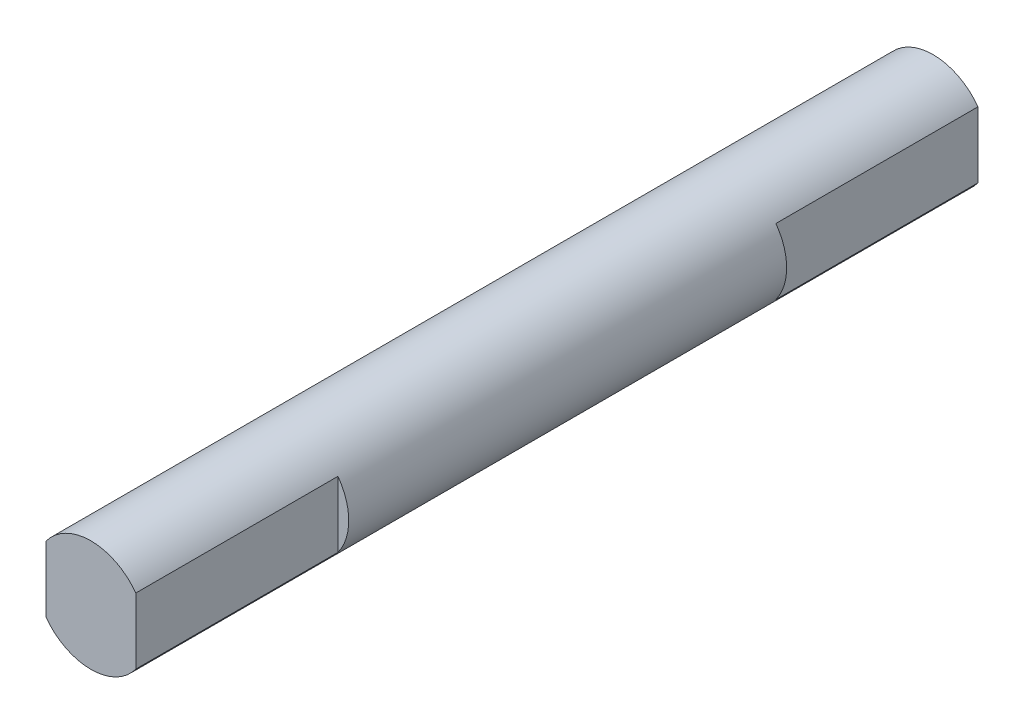
from build123d import *

# Parameters (mm, degrees)
SKETCH1_R                = 2.48
BOSS_EXTRUDE1_DEPTH      = 11
BOSS_EXTRUDE1_DEPTH_BACK = 5
SKETCH2_R                = 2.48
BOSS_EXTRUDE2_DEPTH      = 2
BOSS_EXTRUDE3_DEPTH      = 9
SKETCH4_R                = 2.48
BOSS_EXTRUDE4_DEPTH      = 1.5
BOSS_EXTRUDE5_DEPTH      = 9


with BuildPart() as part:
    # Sketch1 → Boss-Extrude1 (new body, two sides)
    with BuildSketch(Plane.XY) as boss_extrude1_sk:
        Circle(SKETCH1_R)
    extrude(amount=BOSS_EXTRUDE1_DEPTH)
    extrude(boss_extrude1_sk.sketch, amount=-BOSS_EXTRUDE1_DEPTH_BACK)

    # Sketch2 → Boss-Extrude2 (add)
    with BuildSketch(Plane.XY.offset(11)):
        Circle(SKETCH2_R)
    extrude(amount=BOSS_EXTRUDE2_DEPTH)

    # Sketch3 → Boss-Extrude3 (add)
    with BuildSketch(Plane.XY.offset(13)):
        with BuildLine():
            ThreePointArc((2, 1.466424222), (0, 2.48), (-2, 1.466424222))
            Line((-2, 1.466424222), (-2, -1.466424222))
            ThreePointArc((-2, -1.466424222), (0, -2.48), (2, -1.466424222))
            Line((2, -1.466424222), (2, 1.466424222))
        make_face()
    extrude(amount=BOSS_EXTRUDE3_DEPTH)

    # Sketch4 → Boss-Extrude4 (add)
    with BuildSketch(Plane(origin=(0, 0, -5), x_dir=(-1, 0, 0), z_dir=(0, 0, -1))):
        Circle(SKETCH4_R)
    extrude(amount=BOSS_EXTRUDE4_DEPTH)

    # Sketch5 → Boss-Extrude5 (add)
    with BuildSketch(Plane(origin=(0, 0, -6.5), x_dir=(-1, 0, 0), z_dir=(0, 0, -1))):
        with BuildLine():
            ThreePointArc((2, 1.466424222), (0, 2.48), (-2, 1.466424222))
            Line((-2, 1.466424222), (-2, -1.466424222))
            ThreePointArc((-2, -1.466424222), (0, -2.48), (2, -1.466424222))
            Line((2, -1.466424222), (2, 1.466424222))
        make_face()
    extrude(amount=BOSS_EXTRUDE5_DEPTH)


solid = part.part
